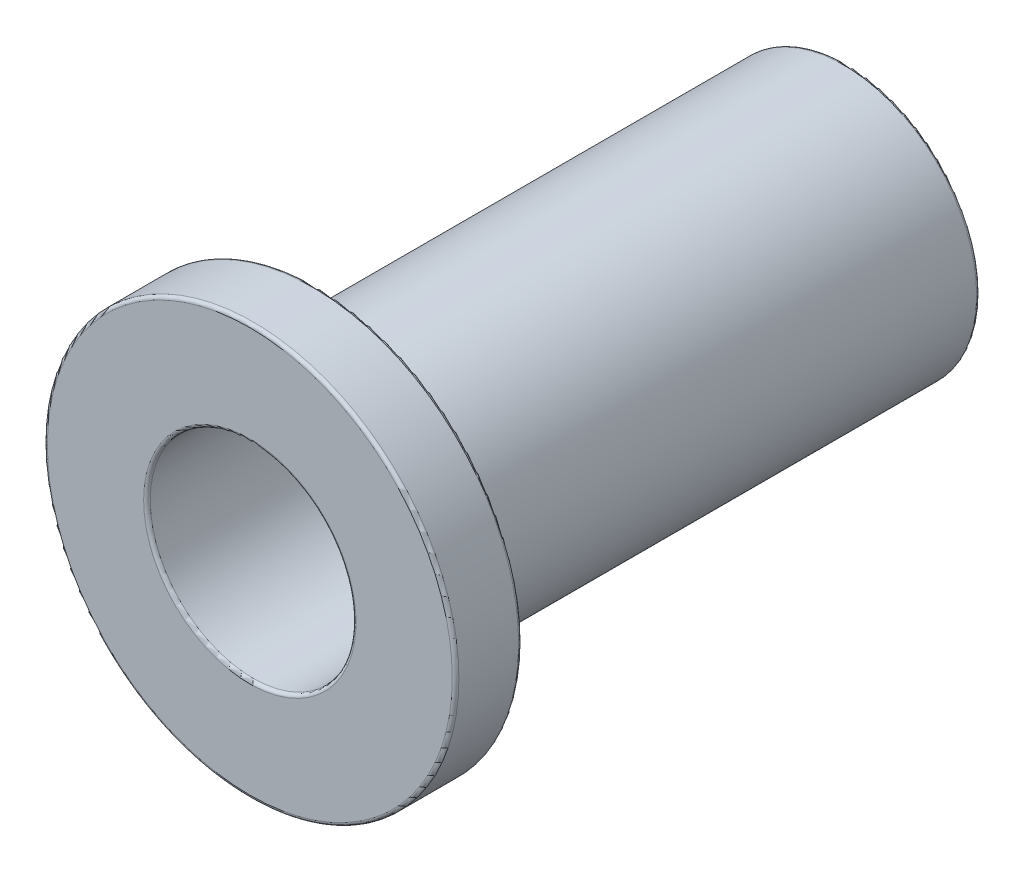
from build123d import *

# Parameters (mm, degrees)
FILLET1_R = 0.05


with BuildPart() as part:
    # Sketch2 → Revolve1 (revolve)
    with BuildSketch(Plane(origin=(0, 0, 0), x_dir=(0, 0, -1), z_dir=(1, 0, 0))):
        Polygon((-4.5, 1.55), (4.5, 1.55), (4.5, 2), (-3.5, 2), (-3.5, 3.1), (-4.5, 3.1), align=None)
    revolve(axis=Axis((0, 0, 4.5), (0, 0, -1)))

    # Fillet1
    fillet1_edges = [part.edges().sort_by_distance(p)[0] for p in [
        (0, -3.1, 4.5),
        (0, -3.1, 3.5),
        (0, -2, 3.5),
        (0, -2, -4.5),
        (0, -1.55, -4.5),
        (0, -1.55, 4.5),
    ]]
    fillet(fillet1_edges, radius=FILLET1_R)


solid = part.part
